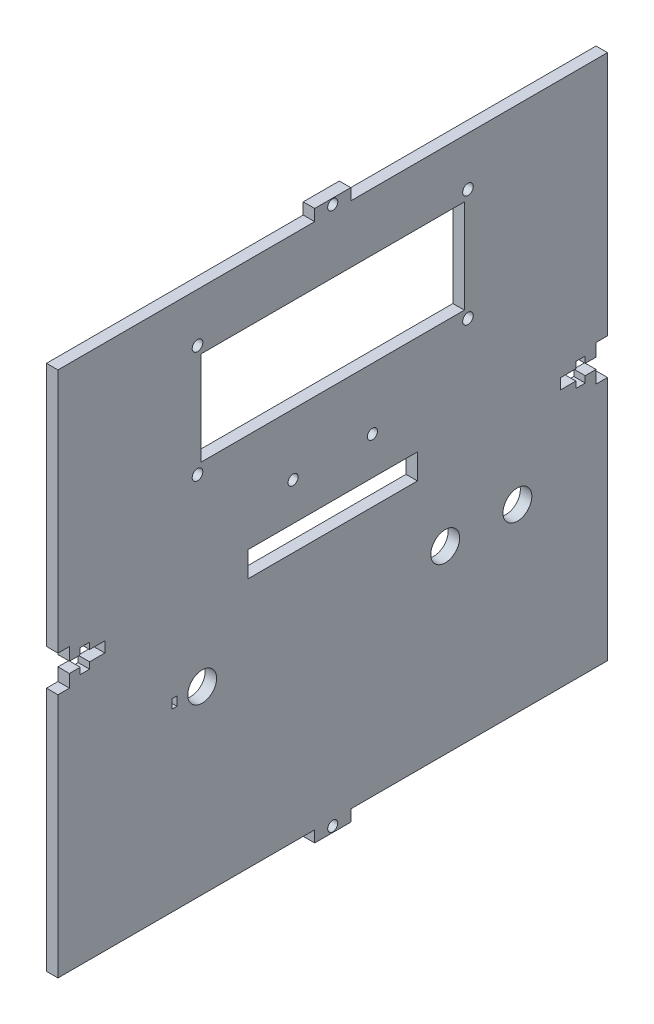
from build123d import *

# Parameters (mm, degrees)
SKETCH1_W               = 152.4
SKETCH1_H               = 146.04
BOSS_EXTRUDE1_DEPTH     = 3.18
SKETCH3_R               = 1.4
SKETCH3_W               = 10
SKETCH3_H               = 3.18
BOSS_EXTRUDE5_DEPTH     = 3.18
CUT_EXTRUDE2_DEPTH      = 4.18
CUT_EXTRUDE3_DEPTH      = 4.18
SKETCH6_W               = 73
SKETCH6_H               = 26
CUT_EXTRUDE4_DEPTH      = 10
SKETCH7_R               = 1.47
CUT_EXTRUDE5_DEPTH      = 4.18
SKETCH8_R               = 4
CUT_EXTRUDE6_DEPTH      = 4.18
SKETCH9_W               = 47
SKETCH9_H               = 7
CUT_EXTRUDE7_DEPTH      = 1
CUT_EXTRUDE7_DEPTH_BACK = 4.18
SKETCH10_W              = 1.31
SKETCH10_H              = 2.5
CUT_EXTRUDE8_DEPTH      = 4.18
SKETCH11_R              = 1.4
CUT_EXTRUDE9_DEPTH      = 4.18


with BuildPart() as part:
    # Sketch1 → Boss-Extrude1 (new body)
    with BuildSketch(Plane(origin=(0, 0, 0), x_dir=(0, 0, -1), z_dir=(1, 0, 0))):
        Rectangle(SKETCH1_W, SKETCH1_H)
    extrude(amount=BOSS_EXTRUDE1_DEPTH)

    # Sketch3 → Boss-Extrude5 (add)
    with BuildSketch(Plane.ZY):
        Polygon((0, 73.02), (5, 73.02), (5, 76.2), (-5, 76.2), (-5, 73.02), align=None)
        with Locations((0, 74.61)):
            Circle(SKETCH3_R, mode=Mode.SUBTRACT)
        with Locations((0, -74.61)):
            Rectangle(SKETCH3_W, SKETCH3_H)
        with Locations((0, -74.61)):
            Circle(SKETCH3_R, mode=Mode.SUBTRACT)
    extrude(amount=-BOSS_EXTRUDE5_DEPTH)

    # Sketch4 → Cut-Extrude2 (cut, through all)
    with BuildSketch(Plane(origin=(0, 0, 0), x_dir=(0, 0, -1), z_dir=(1, 0, 0))):
        Polygon((-76.2, -5), (-76.2, 5), (-73.02, 5), (-73.02, 1.47), (-70.02, 1.47), (-70.02, 3.25), (-67.42, 3.25), (-67.42, 1.47), (-63.2, 1.47), (-63.2, -1.47), (-67.42, -1.47), (-67.42, -3.25), (-70.02, -3.25), (-70.02, -1.47), (-73.02, -1.47), (-73.02, -5), align=None)
    extrude(amount=CUT_EXTRUDE2_DEPTH, mode=Mode.SUBTRACT)

    # Sketch5 → Cut-Extrude3 (cut, through all)
    with BuildSketch(Plane.ZY):
        Polygon((-70.02, -1.47), (-73.02, -1.47), (-73.02, -5), (-76.2, -5), (-76.2, 5), (-73.02, 5), (-73.02, 1.47), (-70.02, 1.47), (-70.02, 3.25), (-67.42, 3.25), (-67.42, 1.47), (-63.2, 1.47), (-63.2, -1.47), (-67.42, -1.47), (-67.42, -3.25), (-70.02, -3.25), align=None)
    extrude(amount=-CUT_EXTRUDE3_DEPTH, mode=Mode.SUBTRACT)

    # Sketch6 → Cut-Extrude4 (cut)
    with BuildSketch(Plane.ZY):
        with Locations((0, 44.02)):
            Rectangle(SKETCH6_W, SKETCH6_H)
    extrude(amount=-CUT_EXTRUDE4_DEPTH, mode=Mode.SUBTRACT)

    # Sketch7 → Cut-Extrude5 (cut, through all)
    with BuildSketch(Plane.ZY):
        with Locations((-37.5, 59.52)):
            Circle(SKETCH7_R)
        with Locations((-37.5, 28.52)):
            Circle(SKETCH7_R)
        with Locations((37.5, 59.52)):
            Circle(SKETCH7_R)
        with Locations((37.5, 28.52)):
            Circle(SKETCH7_R)
    extrude(amount=-CUT_EXTRUDE5_DEPTH, mode=Mode.SUBTRACT)

    # Sketch8 → Cut-Extrude6 (cut, through all)
    with BuildSketch(Plane.ZY):
        with Locations((-51.2, -23.02)):
            Circle(SKETCH8_R)
        with Locations((-31.2, -23.02)):
            Circle(SKETCH8_R)
        with Locations((36.2, -23.02)):
            Circle(SKETCH8_R)
    extrude(amount=-CUT_EXTRUDE6_DEPTH, mode=Mode.SUBTRACT)

    # Sketch9 → Cut-Extrude7 (cut, two sides)
    with BuildSketch(Plane.ZY) as cut_extrude7_sk:
        Rectangle(SKETCH9_W, SKETCH9_H)
    extrude(amount=CUT_EXTRUDE7_DEPTH, mode=Mode.SUBTRACT)
    extrude(cut_extrude7_sk.sketch, amount=-CUT_EXTRUDE7_DEPTH_BACK, mode=Mode.SUBTRACT)

    # Sketch10 → Cut-Extrude8 (cut, through all)
    with BuildSketch(Plane.ZY):
        with Locations((43.855, -23.02)):
            Rectangle(SKETCH10_W, SKETCH10_H)
    extrude(amount=-CUT_EXTRUDE8_DEPTH, mode=Mode.SUBTRACT)

    # Sketch11 → Cut-Extrude9 (cut, through all)
    with BuildSketch(Plane.ZY):
        with Locations((-11, 14.02)):
            Circle(SKETCH11_R)
        with Locations((11, 14.02)):
            Circle(SKETCH11_R)
    extrude(amount=-CUT_EXTRUDE9_DEPTH, mode=Mode.SUBTRACT)


solid = part.part
